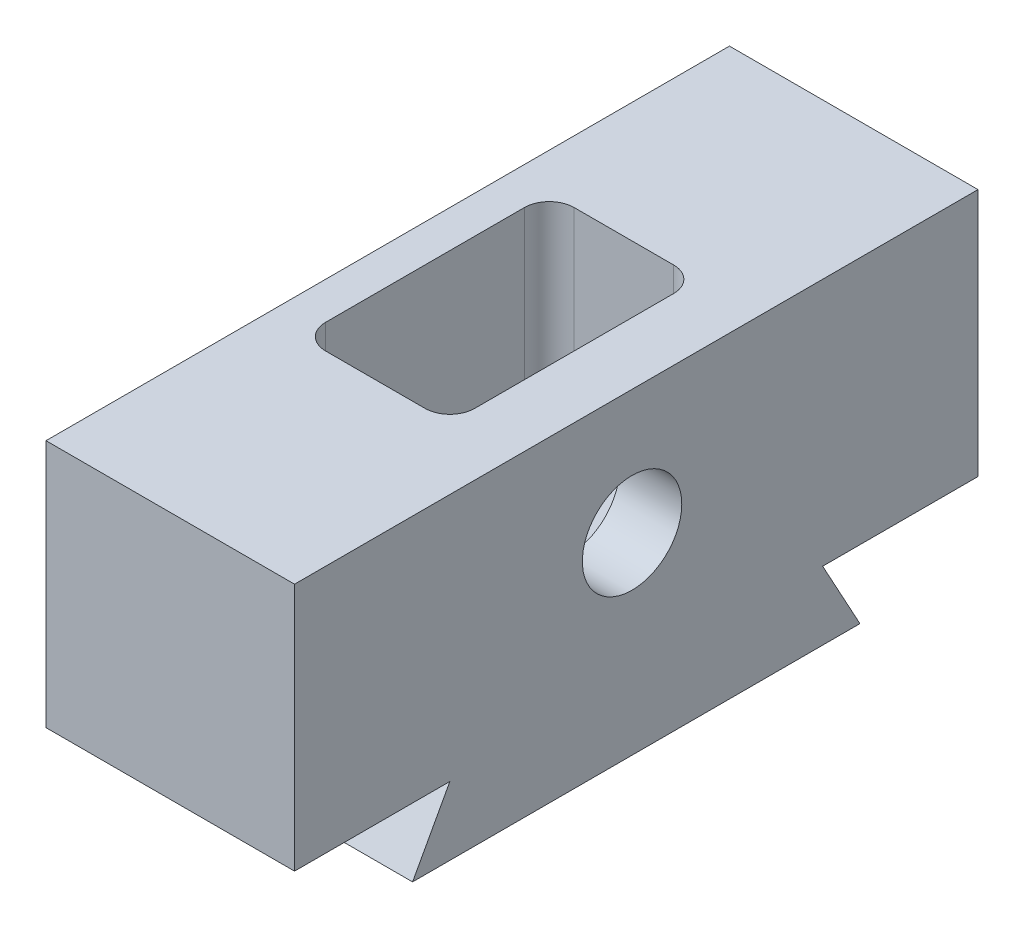
from build123d import *

# Parameters (mm, degrees)
BOSS_EXTRUDE1_DEPTH             = 10
F_8_0MM_DOWEL_HOLE2_D           = 8
F_8_0MM_DOWEL_HOLE2_DEPTH       = 5
TAP_DRILL_FOR_M5X0_8_TAP1_D     = 4.2
TAP_DRILL_FOR_M5X0_8_TAP1_DEPTH = 10
TAP_DRILL_FOR_M5X0_8_TAP1_TIP   = 1.2618073
SKETCH7_OUTSIDE_W               = 34.768
SKETCH7_OUTSIDE_H               = 69.768
SKETCH7_OUTSIDE_W_2             = 20
SKETCH7_OUTSIDE_H_2             = 55
CUT_EXTRUDE1_DEPTH              = 16


with BuildPart() as part:
    # Sketch1 → Boss-Extrude1 (new body, symmetric)
    with BuildSketch(Plane(origin=(0, 0, 0), x_dir=(0, 0, -1), z_dir=(1, 0, 0))):
        Polygon((-55, -20), (-42.5, -20), (-45.5, -25.5), (-9.5, -25.5), (-12.5, -20), (0, -20), (0, 0), (-55, 0), align=None)
    extrude(amount=BOSS_EXTRUDE1_DEPTH, both=True)

    # Ø8.0mm Dowel Hole2
    with Locations(Plane(origin=(10, -10, 27.838852212), x_dir=(0, 0, 1), z_dir=(1, 0, 0))):
        with Locations((0, 0)):
            Hole(F_8_0MM_DOWEL_HOLE2_D / 2, depth=F_8_0MM_DOWEL_HOLE2_DEPTH)

    # Tap Drill for M5x0.8 Tap1
    with Locations(Plane(origin=(-10, -9, 10), x_dir=(0, 0, -1), z_dir=(-1, 0, 0))):
        with Locations((0, 0), (-35, 0)):
            Hole(TAP_DRILL_FOR_M5X0_8_TAP1_D / 2, depth=TAP_DRILL_FOR_M5X0_8_TAP1_DEPTH)
            with Locations((0, 0, -(TAP_DRILL_FOR_M5X0_8_TAP1_DEPTH + TAP_DRILL_FOR_M5X0_8_TAP1_TIP / 2))):  # 118° drill point
                Cone(0, TAP_DRILL_FOR_M5X0_8_TAP1_D / 2, TAP_DRILL_FOR_M5X0_8_TAP1_TIP, mode=Mode.SUBTRACT)

    # Sketch7 outside → Cut-Extrude1 (cut)
    with BuildSketch(Plane(origin=(0, 0, 0), x_dir=(1, 0, 0), z_dir=(0, 1, 0))):
        with Locations((0, -27.5)):
            Rectangle(SKETCH7_OUTSIDE_W, SKETCH7_OUTSIDE_H)
        with Locations((0, -27.5)):
            Rectangle(SKETCH7_OUTSIDE_W_2, SKETCH7_OUTSIDE_H_2, mode=Mode.SUBTRACT)
        with BuildLine():
            Line((3, -17.5), (-5, -17.5))
            ThreePointArc((-5, -17.5), (-6.414213562, -18.085786438), (-7, -19.5))
            Line((-7, -19.5), (-7, -35.5))
            ThreePointArc((-7, -35.5), (-6.414213562, -36.914213562), (-5, -37.5))
            Line((-5, -37.5), (3, -37.5))
            ThreePointArc((3, -37.5), (4.414213562, -36.914213562), (5, -35.5))
            Line((5, -35.5), (5, -19.5))
            ThreePointArc((5, -19.5), (4.414213562, -18.085786438), (3, -17.5))
        make_face()
    extrude(amount=-CUT_EXTRUDE1_DEPTH, mode=Mode.SUBTRACT)


solid = part.part
